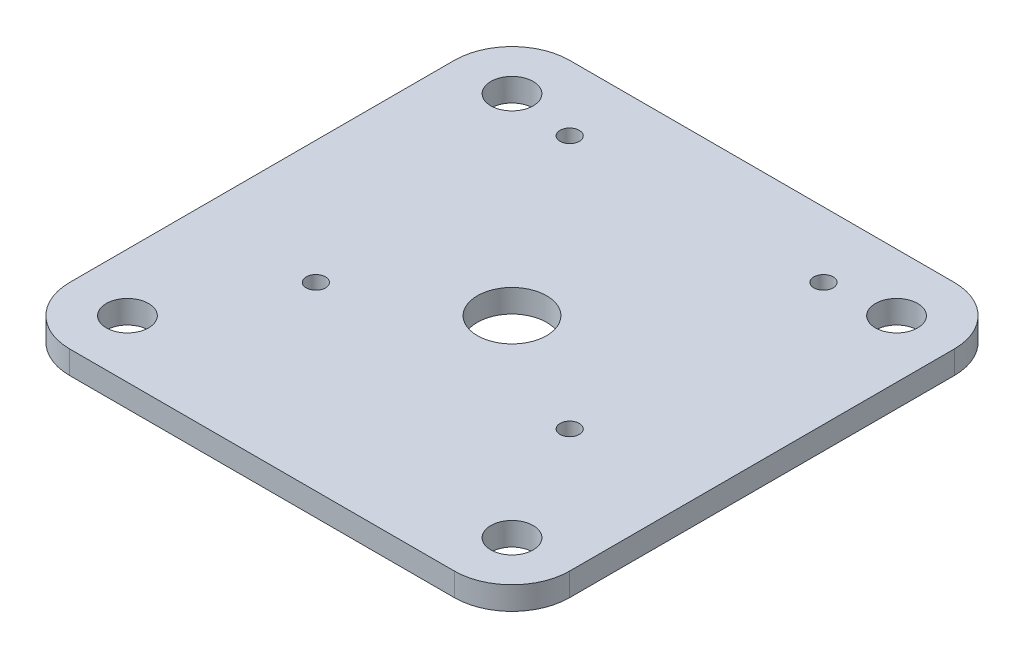
from build123d import *

# Parameters (mm, degrees)
SKETCH1_R               = 9
BOSS_EXTRUDE1_DEPTH     = 6
SKETCH3_R               = 5.5
CUT_EXTRUDE2_DEPTH      = 1
CUT_EXTRUDE2_DEPTH_BACK = 7
CUT_EXTRUDE3_REACH      = 8
SKETCH6_R               = 2.5


with BuildPart() as part:
    # Sketch1 → Boss-Extrude1 (new body)
    with BuildSketch(Plane(origin=(0, 0, 0), x_dir=(1, 0, 0), z_dir=(0, 1, 0))):
        with BuildLine():
            Line((-50, -65), (50, -65))
            ThreePointArc((50, -65), (60.606601718, -60.606601718), (65, -50))
            Line((65, -50), (65, 50))
            ThreePointArc((65, 50), (60.606601718, 60.606601718), (50, 65))
            Line((50, 65), (-50, 65))
            ThreePointArc((-50, 65), (-60.606601718, 60.606601718), (-65, 50))
            Line((-65, 50), (-65, -50))
            ThreePointArc((-65, -50), (-60.606601718, -60.606601718), (-50, -65))
        make_face()
        Circle(SKETCH1_R, mode=Mode.SUBTRACT)
    extrude(amount=BOSS_EXTRUDE1_DEPTH)

    # Sketch3 → Cut-Extrude2 (cut, two sides)
    with BuildSketch(Plane(origin=(0, 6, 0), x_dir=(1, 0, 0), z_dir=(0, 1, 0))) as cut_extrude2_sk:
        with Locations((-50, 50)):
            Circle(SKETCH3_R)
        with Locations((50, 50)):
            Circle(SKETCH3_R)
        with Locations((50, -50)):
            Circle(SKETCH3_R)
        with Locations((-50, -50)):
            Circle(SKETCH3_R)
    extrude(amount=CUT_EXTRUDE2_DEPTH, mode=Mode.SUBTRACT)
    extrude(cut_extrude2_sk.sketch, amount=-CUT_EXTRUDE2_DEPTH_BACK, mode=Mode.SUBTRACT)

    # Sketch6 → Cut-Extrude3 (cut, up to next)
    with BuildSketch(Plane(origin=(0, 6, 0), x_dir=(1, 0, 0), z_dir=(0, 1, 0)), mode=Mode.PRIVATE) as cut_extrude3_sk1:
        with Locations((33, 48)):
            Circle(SKETCH6_R)
    cut_extrude3_tool1 = extrude(cut_extrude3_sk1.sketch, amount=-CUT_EXTRUDE3_REACH, mode=Mode.PRIVATE) & part.part
    add(cut_extrude3_tool1.solids().sort_by_distance((33, 6, -48))[0], mode=Mode.SUBTRACT)
    # Sketch6 → Cut-Extrude3 (cut, up to next)
    with BuildSketch(Plane(origin=(0, 6, 0), x_dir=(1, 0, 0), z_dir=(0, 1, 0)), mode=Mode.PRIVATE) as cut_extrude3_sk2:
        with Locations((33, -18)):
            Circle(SKETCH6_R)
    cut_extrude3_tool2 = extrude(cut_extrude3_sk2.sketch, amount=-CUT_EXTRUDE3_REACH, mode=Mode.PRIVATE) & part.part
    add(cut_extrude3_tool2.solids().sort_by_distance((33, 6, 18))[0], mode=Mode.SUBTRACT)
    # Sketch6 → Cut-Extrude3 (cut, up to next)
    with BuildSketch(Plane(origin=(0, 6, 0), x_dir=(1, 0, 0), z_dir=(0, 1, 0)), mode=Mode.PRIVATE) as cut_extrude3_sk3:
        with Locations((-33, 48)):
            Circle(SKETCH6_R)
    cut_extrude3_tool3 = extrude(cut_extrude3_sk3.sketch, amount=-CUT_EXTRUDE3_REACH, mode=Mode.PRIVATE) & part.part
    add(cut_extrude3_tool3.solids().sort_by_distance((-33, 6, -48))[0], mode=Mode.SUBTRACT)
    # Sketch6 → Cut-Extrude3 (cut, up to next)
    with BuildSketch(Plane(origin=(0, 6, 0), x_dir=(1, 0, 0), z_dir=(0, 1, 0)), mode=Mode.PRIVATE) as cut_extrude3_sk4:
        with Locations((-33, -18)):
            Circle(SKETCH6_R)
    cut_extrude3_tool4 = extrude(cut_extrude3_sk4.sketch, amount=-CUT_EXTRUDE3_REACH, mode=Mode.PRIVATE) & part.part
    add(cut_extrude3_tool4.solids().sort_by_distance((-33, 6, 18))[0], mode=Mode.SUBTRACT)


solid = part.part
